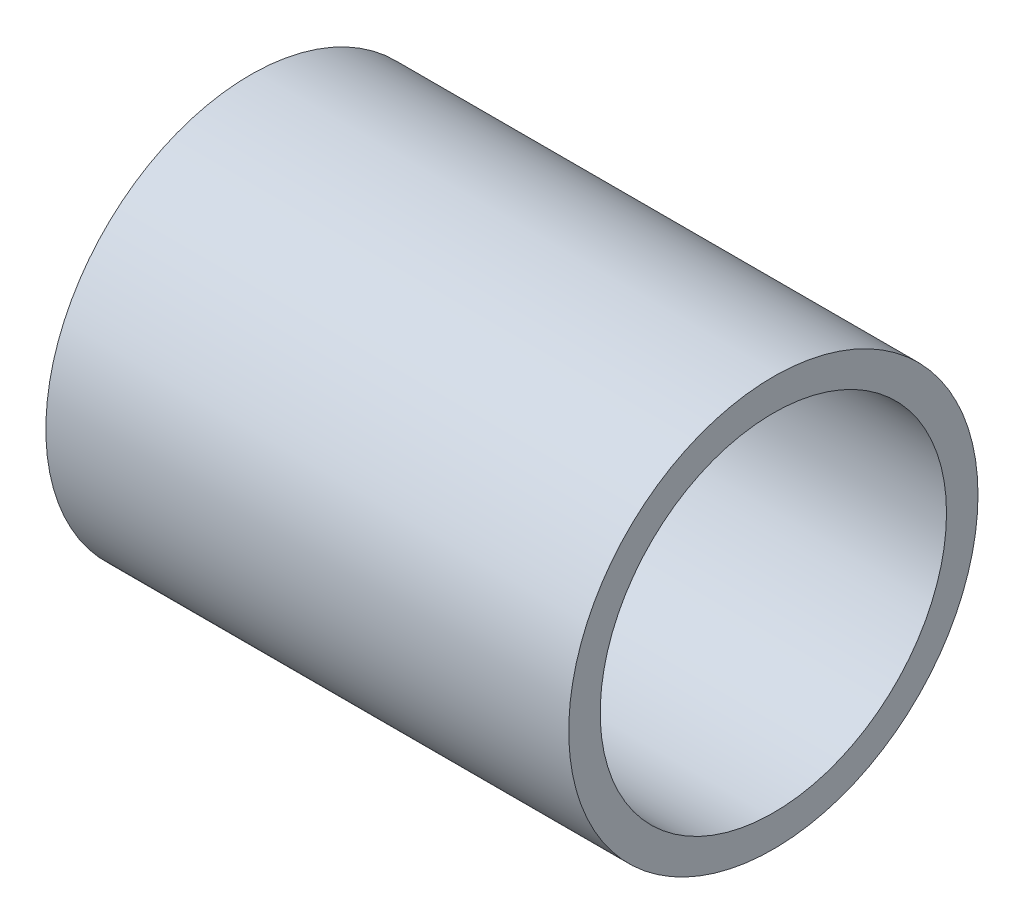
from build123d import *

# Parameters (mm, degrees)
SKETCH1_R           = 32.5
SKETCH1_R_2         = 27.5
BOSS_EXTRUDE1_DEPTH = 83.04


with BuildPart() as part:
    # Sketch1 → Boss-Extrude1 (new body)
    with BuildSketch(Plane(origin=(0, 0, 0), x_dir=(0, 0, -1), z_dir=(1, 0, 0))):
        Circle(SKETCH1_R)
        Circle(SKETCH1_R_2, mode=Mode.SUBTRACT)
    extrude(amount=BOSS_EXTRUDE1_DEPTH)


solid = part.part
